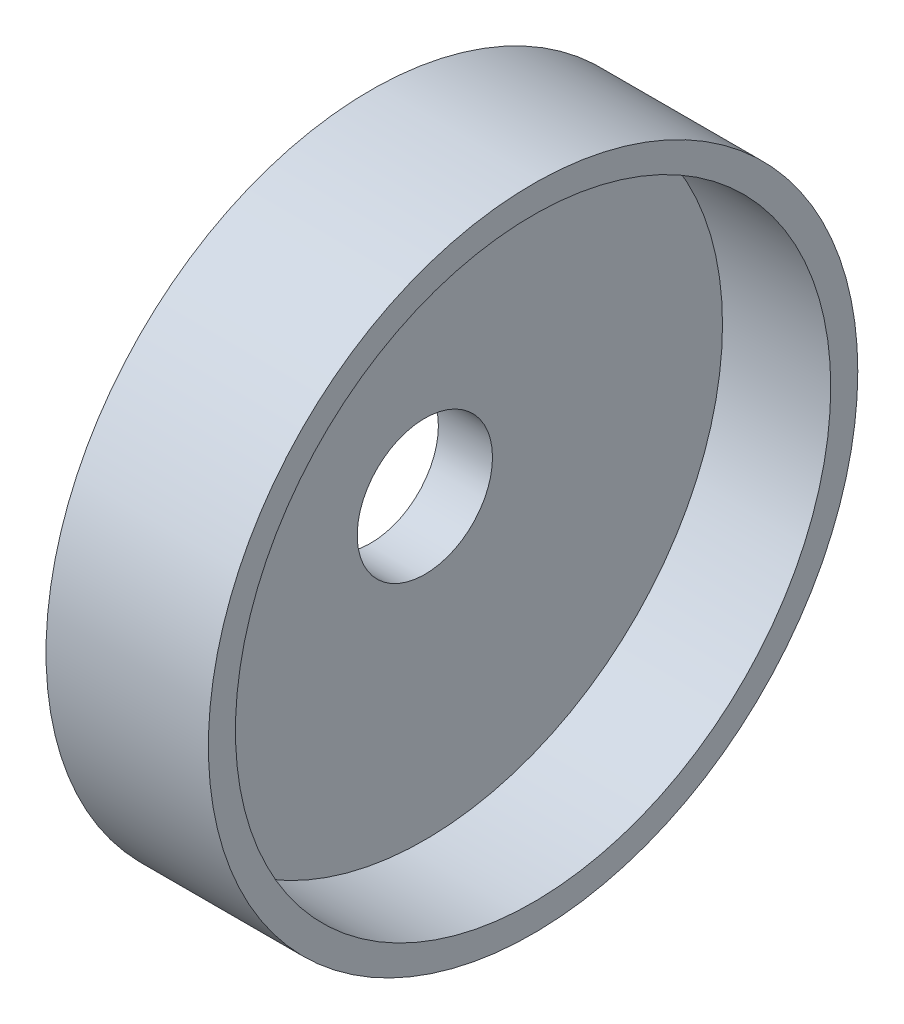
from build123d import *

# Parameters (mm, degrees)
SKETCH1_R           = 60
BOSS_EXTRUDE1_DEPTH = 10
SKETCH2_R           = 60
SKETCH2_R_2         = 55
BOSS_EXTRUDE2_DEPTH = 20
SKETCH3_R           = 12.5
CUT_EXTRUDE1_DEPTH  = 11


with BuildPart() as part:
    # Sketch1 → Boss-Extrude1 (new body)
    with BuildSketch(Plane(origin=(0, 0, 0), x_dir=(0, 0, -1), z_dir=(1, 0, 0))):
        Circle(SKETCH1_R)
    extrude(amount=BOSS_EXTRUDE1_DEPTH)

    # Sketch2 → Boss-Extrude2 (add)
    with BuildSketch(Plane(origin=(10, 0, 0), x_dir=(0, 0, -1), z_dir=(1, 0, 0))):
        Circle(SKETCH2_R)
        Circle(SKETCH2_R_2, mode=Mode.SUBTRACT)
    extrude(amount=BOSS_EXTRUDE2_DEPTH)

    # Sketch3 → Cut-Extrude1 (cut, through all)
    with BuildSketch(Plane(origin=(10, 0, 0), x_dir=(0, 0, -1), z_dir=(1, 0, 0))):
        Circle(SKETCH3_R)
    extrude(amount=-CUT_EXTRUDE1_DEPTH, mode=Mode.SUBTRACT)


solid = part.part
